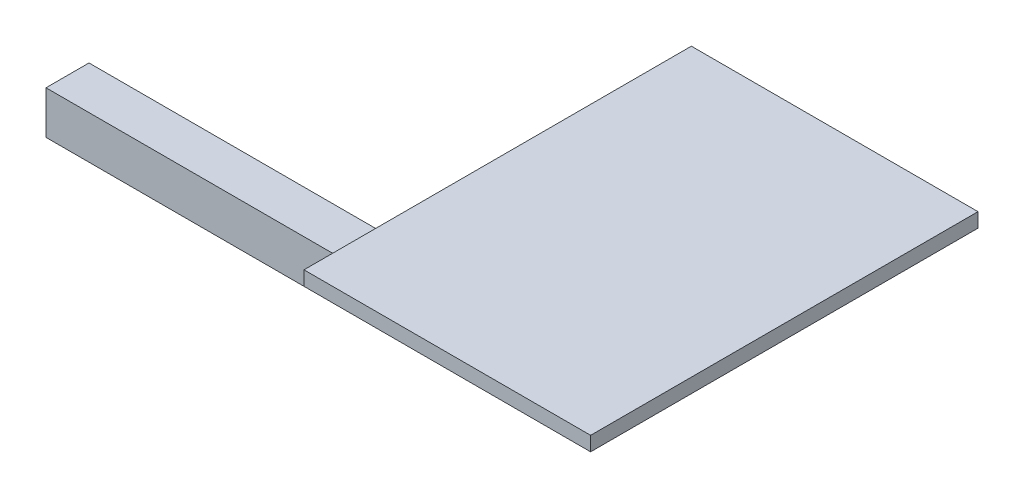
from build123d import *

# Parameters (mm, degrees)
SKETCH1_W      = 200
SKETCH1_H      = 270.285174582
EXTRUDE1_DEPTH = 10
SKETCH2_W      = 30
SKETCH2_H      = 30
EXTRUDE2_DEPTH = 100
SKETCH3_W      = 30
SKETCH3_H      = 30
EXTRUDE3_DEPTH = 330


with BuildPart() as part:
    # Sketch1 → Extrude1 (new body)
    with BuildSketch(Plane(origin=(0, 0, 0), x_dir=(1, 0, 0), z_dir=(0, 1, 0))):
        with Locations((-100, 135.142587291)):
            Rectangle(SKETCH1_W, SKETCH1_H)
    extrude(amount=EXTRUDE1_DEPTH)

    # Sketch2 → Extrude2 (add)
    with BuildSketch(Plane.XZ):
        with Locations((-135, -115)):
            Rectangle(SKETCH2_W, SKETCH2_H)
    extrude(amount=EXTRUDE2_DEPTH)

    # Sketch3 → Extrude3 (add)
    with BuildSketch(Plane.ZY.offset(150)):
        with Locations((-115, -85)):
            Rectangle(SKETCH3_W, SKETCH3_H)
    extrude(amount=EXTRUDE3_DEPTH)


solid = part.part
